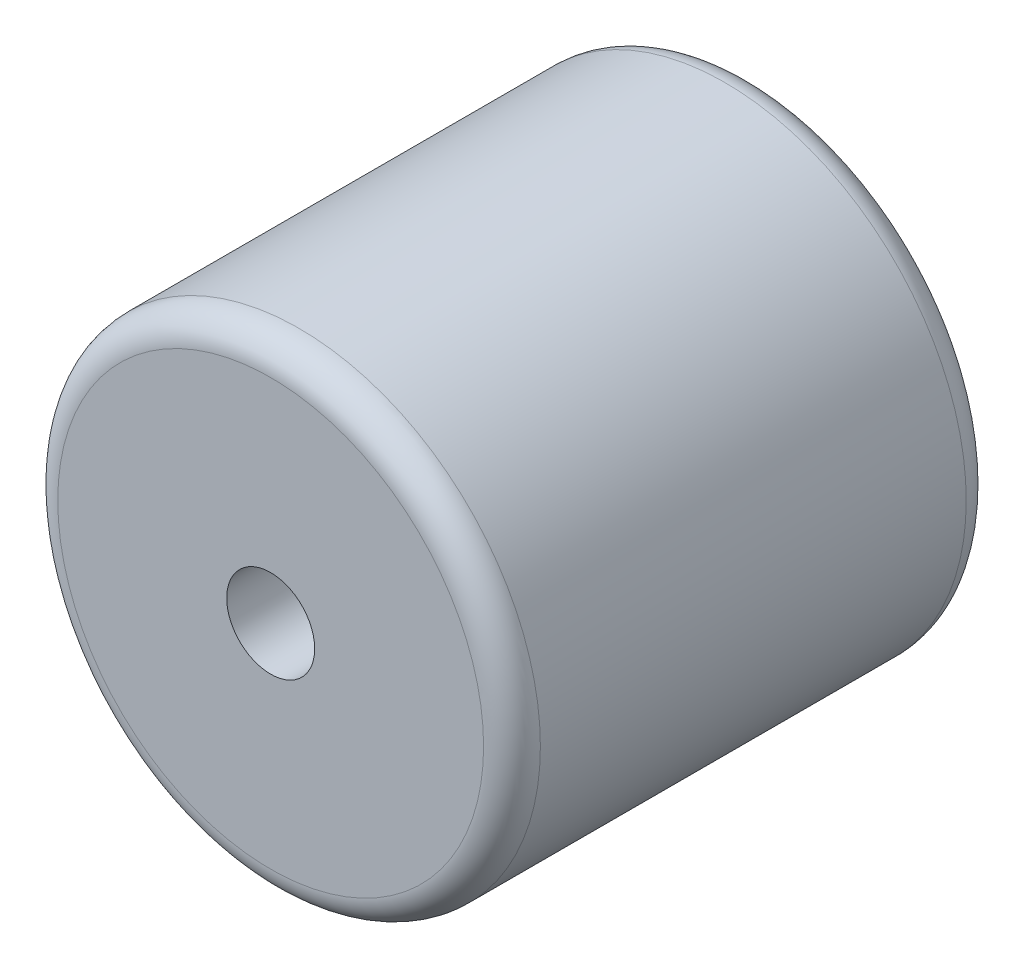
from build123d import *

# Parameters (mm, degrees)
SKETCH1_R           = 8.5
SKETCH1_R_2         = 1.55
BOSS_EXTRUDE1_DEPTH = 8.5
FILLET1_R           = 1


with BuildPart() as part:
    # Sketch1 → Boss-Extrude1 (new body, symmetric)
    with BuildSketch(Plane.XY):
        Circle(SKETCH1_R)
        Circle(SKETCH1_R_2, mode=Mode.SUBTRACT)
    extrude(amount=BOSS_EXTRUDE1_DEPTH, both=True)

    # Fillet1
    fillet1_edges = [part.edges().sort_by_distance(p)[0] for p in [
        (-8.5, 0, -8.5),
        (-8.5, 0, 8.5),
    ]]
    fillet(fillet1_edges, radius=FILLET1_R)


solid = part.part
